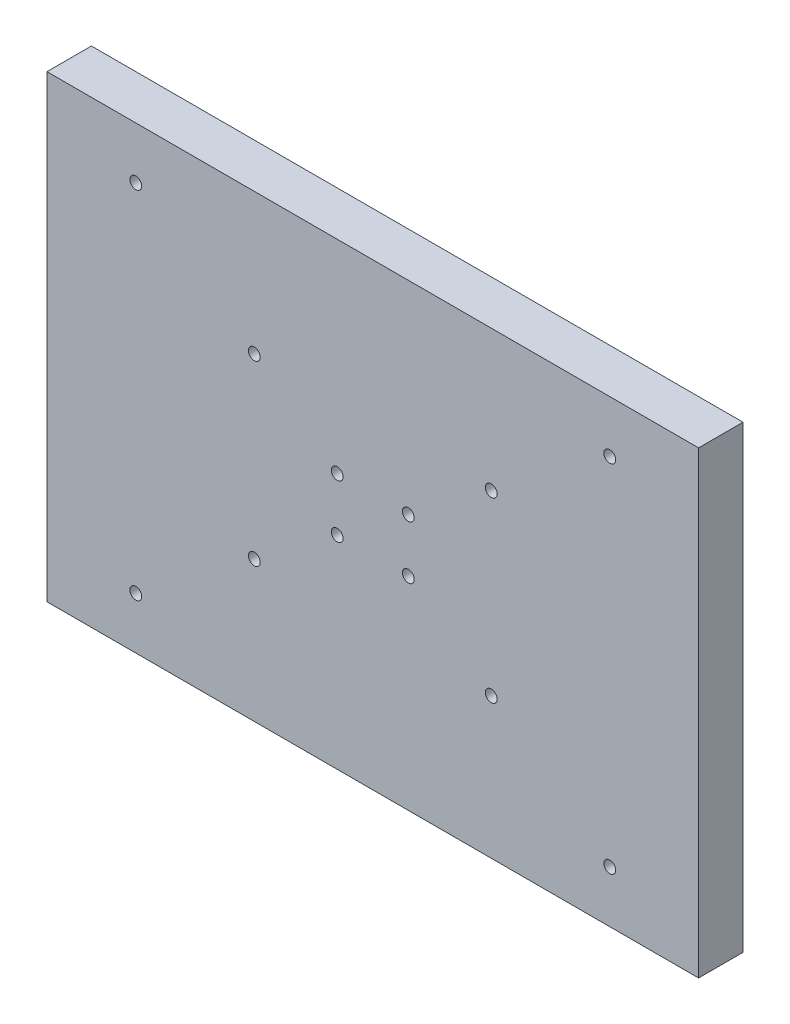
from build123d import *

# Parameters (mm, degrees)
SKETCH1_W           = 220
SKETCH1_H           = 155
SKETCH1_R           = 2
BOSS_EXTRUDE1_DEPTH = 15


with BuildPart() as part:
    # Sketch1 → Boss-Extrude1 (new body)
    with BuildSketch(Plane.XY):
        with Locations((-327.751680005, -52.377216901)):
            Rectangle(SKETCH1_W, SKETCH1_H)
        with Locations((-315.751680005, -61.377216901)):
            Circle(SKETCH1_R, mode=Mode.SUBTRACT)
        with Locations((-339.751680005, -61.377216901)):
            Circle(SKETCH1_R, mode=Mode.SUBTRACT)
        with Locations((-315.751680005, -43.377216901)):
            Circle(SKETCH1_R, mode=Mode.SUBTRACT)
        with Locations((-339.751680005, -43.377216901)):
            Circle(SKETCH1_R, mode=Mode.SUBTRACT)
        with Locations((-247.751680005, -112.377216901)):
            Circle(SKETCH1_R, mode=Mode.SUBTRACT)
        with Locations((-407.751680005, -112.377216901)):
            Circle(SKETCH1_R, mode=Mode.SUBTRACT)
        with Locations((-247.751680005, 7.622783099)):
            Circle(SKETCH1_R, mode=Mode.SUBTRACT)
        with Locations((-407.751680005, 7.622783099)):
            Circle(SKETCH1_R, mode=Mode.SUBTRACT)
        with Locations((-287.751680005, -82.377216901)):
            Circle(SKETCH1_R, mode=Mode.SUBTRACT)
        with Locations((-367.751680005, -82.377216901)):
            Circle(SKETCH1_R, mode=Mode.SUBTRACT)
        with Locations((-287.751680005, -22.377216901)):
            Circle(SKETCH1_R, mode=Mode.SUBTRACT)
        with Locations((-367.751680005, -22.377216901)):
            Circle(SKETCH1_R, mode=Mode.SUBTRACT)
    extrude(amount=BOSS_EXTRUDE1_DEPTH)


solid = part.part
